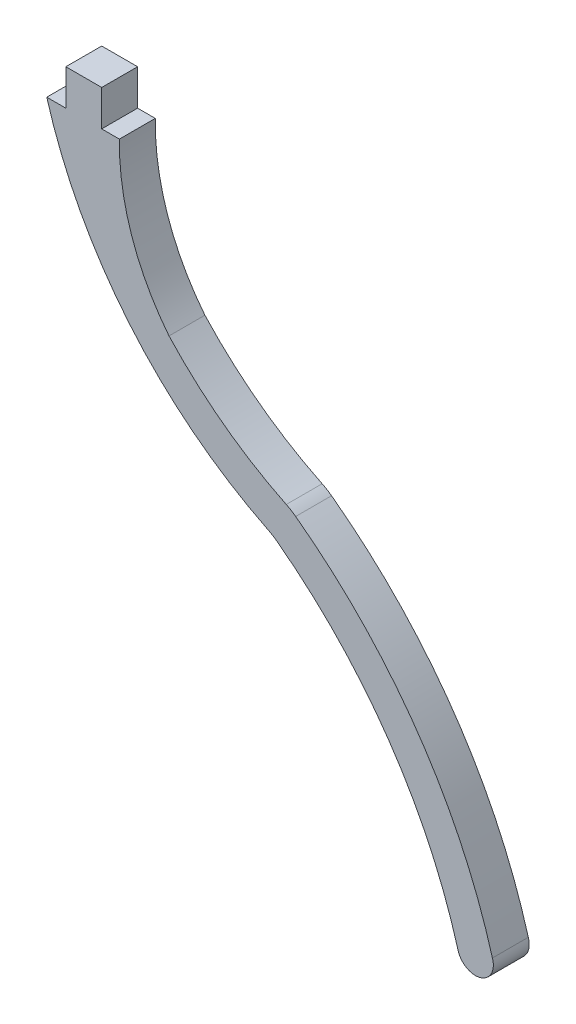
from build123d import *

# Parameters (mm, degrees)
BOSS_EXTRUDE1_DEPTH = 1.524


with BuildPart() as part:
    # Sketch1 → Boss-Extrude1 (new body)
    with BuildSketch(Plane.XY):
        with BuildLine():
            ThreePointArc((12.566304874, -9.8933052), (12.77131161, -10.004957793), (12.965201909, -10.13496016))
            ThreePointArc((12.965201909, -10.13496016), (18.14143902, -15.472865183), (21.320013307, -22.194719552))
            ThreePointArc((21.320013307, -22.194719552), (20.806583347, -23.173609324), (19.854339012, -22.612301713))
            ThreePointArc((19.854339012, -22.612301713), (16.93227249, -16.403886417), (12.182265789, -11.452085777))
            ThreePointArc((12.182265789, -11.452085777), (11.989118214, -11.3205608), (11.784700698, -11.207342939))
            ThreePointArc((11.784700698, -11.207342939), (5.914450191, -6.588756496), (2.396003148, 0))
            Line((2.396003148, 0), (3.20554689, 0))
            Line((3.20554689, 0), (3.20554689, 1.524))
            Line((3.20554689, 1.524), (4.72954689, 1.524))
            Line((4.72954689, 1.524), (4.72954689, 0))
            Line((4.72954689, 0), (5.480406076, 0))
            ThreePointArc((5.480406076, 0), (5.996385034, -3.275905029), (7.587657532, -6.185482298))
            ThreePointArc((7.587657532, -6.185482298), (9.902770623, -8.273313508), (12.566304874, -9.8933052))
        make_face()
    extrude(amount=BOSS_EXTRUDE1_DEPTH)


solid = part.part
